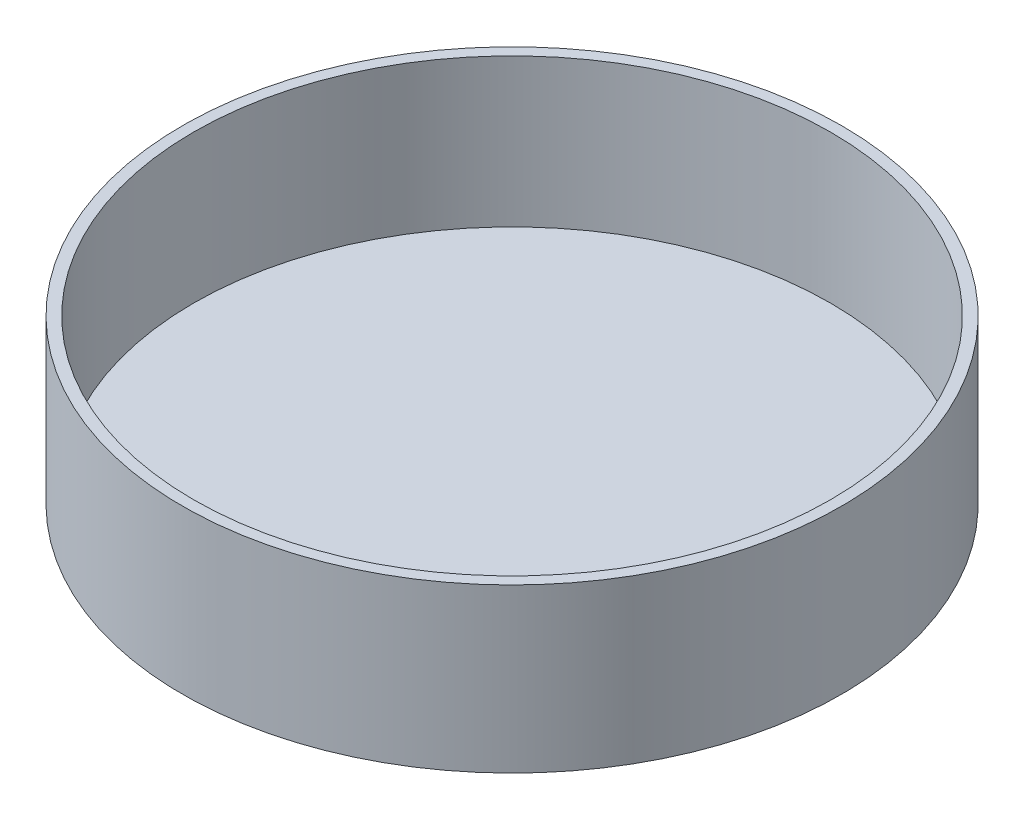
from build123d import *


with BuildPart() as part:
    # Sketch1 → Revolve1 (revolve)
    with BuildSketch(Plane(origin=(0, 0, 0), x_dir=(0, 0, -1), z_dir=(1, 0, 0)), mode=Mode.PRIVATE) as revolve1_sk:
        Polygon((0, 0), (-141.2875, 0), (-141.2875, 69.85), (-136.525, 69.85), (-136.525, 6.35), (0, 6.35), align=None)
    revolve(revolve1_sk.sketch.rotate(Axis((0, -45.633687212, 0), (0, 1, 0)), 180), axis=Axis((0, -45.633687212, 0), (0, 1, 0)))  # turned: the seam where the file's is


solid = part.part
